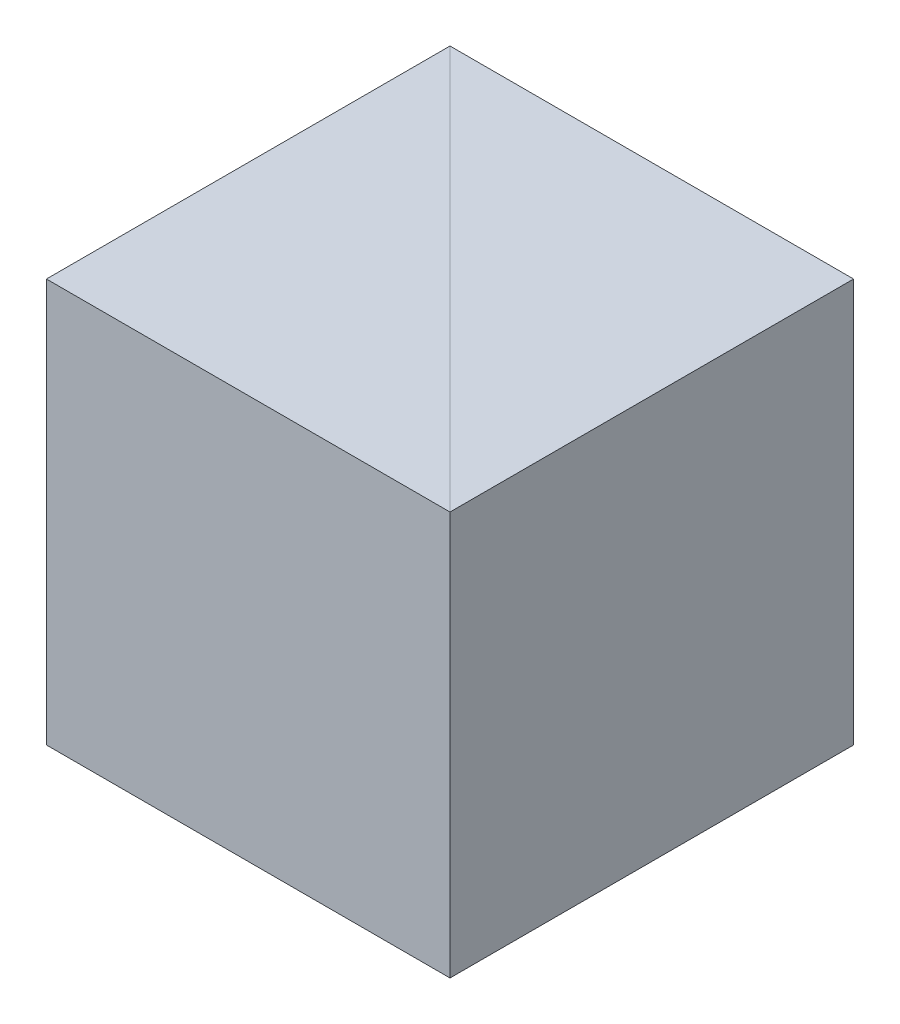
from build123d import *

# Parameters (mm, degrees)
EXTRUDE_1_DEPTH = 10
EXTRUDE_2_DEPTH = 10


with BuildPart() as part:
    # 草图1 → 凸台-拉伸1 (new body)
    with BuildSketch(Plane(origin=(0, 0, 0), x_dir=(1, 0, 0), z_dir=(0, 1, 0))):
        Polygon((0, 0), (0, 10), (-10, 10), align=None)
    extrude(amount=EXTRUDE_1_DEPTH)


with BuildPart() as body_2:
    # 草图2 → 凸台-拉伸2 (new body)
    with BuildSketch(Plane.XZ):
        Polygon((-10, -10), (-10, 0), (0, 0), align=None)
    extrude(amount=-EXTRUDE_2_DEPTH)


solid = Compound([part.part, body_2.part])
